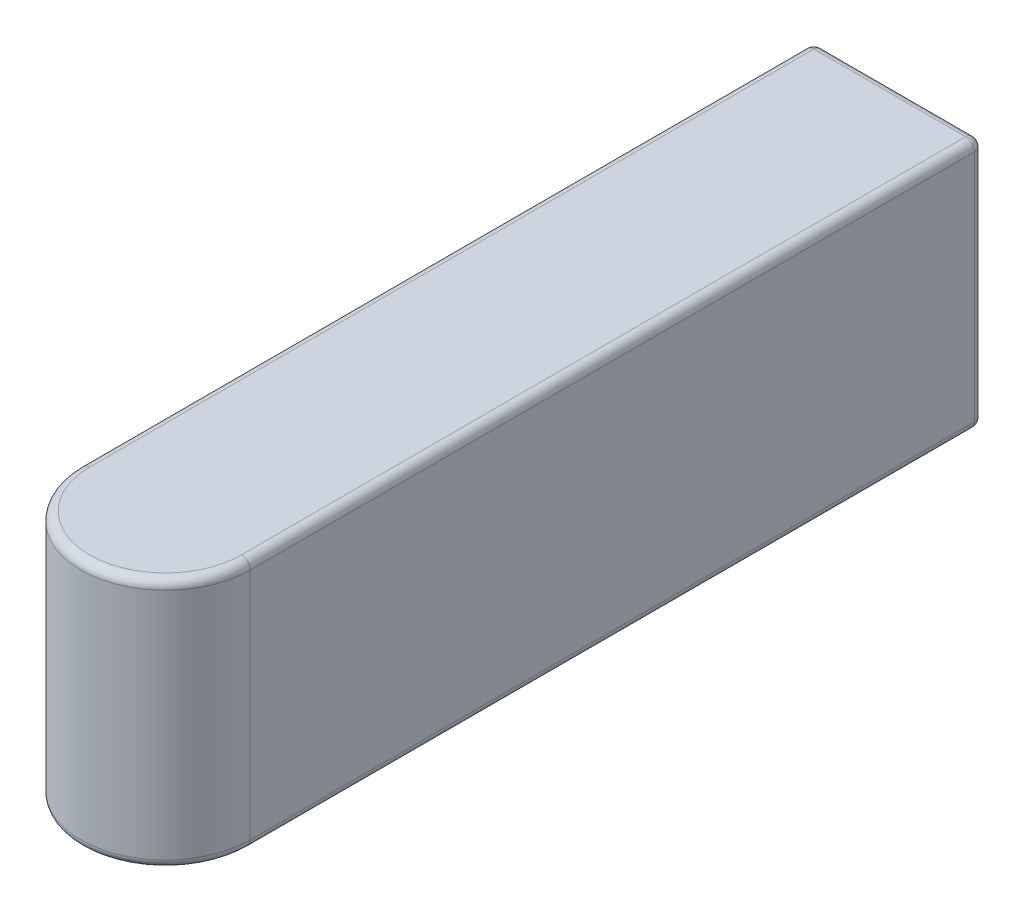
from build123d import *

# Parameters (mm, degrees)
SKETCH1_W           = 29
SKETCH1_H           = 125.5
BOSS_EXTRUDE1_DEPTH = 43
FILLET1_R           = 1.5


with BuildPart() as part:
    # Sketch1 → Boss-Extrude1 (new body)
    with BuildSketch(Plane(origin=(0, 0, 0), x_dir=(1, 0, 0), z_dir=(0, 1, 0))):
        with Locations((14.5, -62.75)):
            Rectangle(SKETCH1_W, SKETCH1_H)
        with BuildLine():
            Line((0, -125.5), (29, -125.5))
            ThreePointArc((29, -125.5), (14.5, -140), (0, -125.5))
        make_face()
    extrude(amount=BOSS_EXTRUDE1_DEPTH)

    # Fillet1
    fillet1_edges = [part.edges().sort_by_distance(p)[0] for p in [
        (14.5, 43, 0),
        (0, 43, 62.75),
        (14.5, 43, 140),
        (29, 43, 62.75),
        (14.5, 0, 140),
        (0, 0, 62.75),
        (14.5, 0, 0),
        (29, 0, 62.75),
        (0, 21.5, 0),
        (29, 21.5, 0),
    ]]
    fillet(fillet1_edges, radius=FILLET1_R)


solid = part.part
